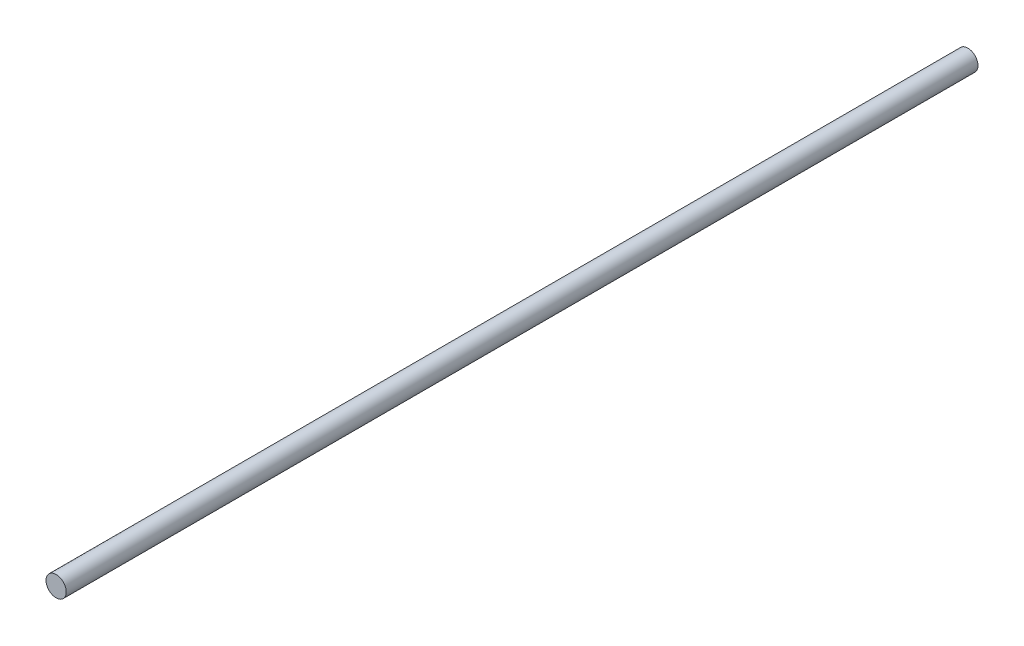
from build123d import *

# Parameters (mm, degrees)
ESQUISSE1_R        = 4
BOSS_EXTRU_1_DEPTH = 360


with BuildPart() as part:
    # Esquisse1 → Boss.-Extru.1 (new body)
    with BuildSketch(Plane.XY):
        Circle(ESQUISSE1_R)
    extrude(amount=BOSS_EXTRU_1_DEPTH)


solid = part.part
